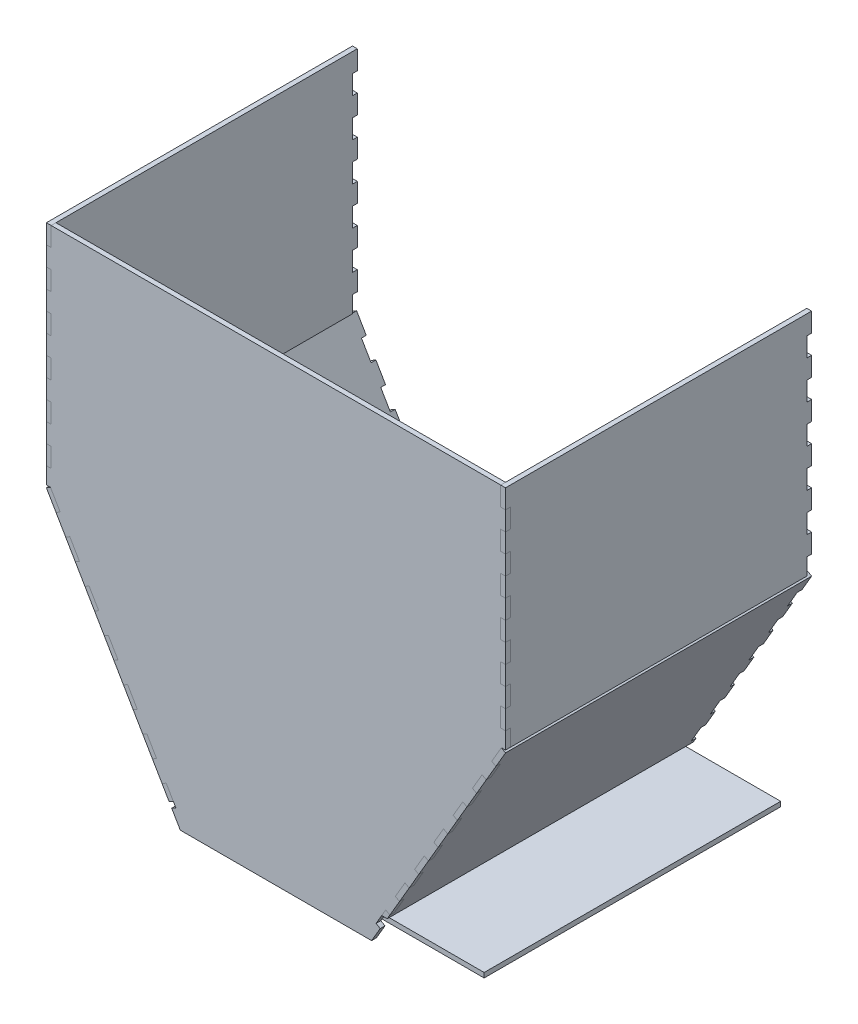
from build123d import *

# Parameters (mm, degrees)
SKETCH1_W               = 304.8
SKETCH1_H               = 152.4
BOSS_EXTRUDE1_DEPTH     = 3.175
SKETCH2_W               = 3.175
SKETCH2_H               = 12.7
CUT_EXTRUDE1_DEPTH      = 3.175
BOSS_EXTRUDE2_DEPTH     = 3.175
BOSS_EXTRUDE3_DEPTH     = 3.175
CUT_EXTRUDE2_DEPTH      = 965.327
CUT_EXTRUDE2_DEPTH_BACK = 965.327
CUT_EXTRUDE3_DEPTH      = 965.327
SKETCH7_W               = 203.2
SKETCH7_H               = 3.175
BOSS_EXTRUDE4_DEPTH     = 196.85


with BuildPart() as part:
    # Sketch1 → Boss-Extrude1 (new body)
    with BuildSketch(Plane.XY):
        Rectangle(SKETCH1_W, SKETCH1_H)
        Polygon((-63.5, -228.6), (63.5, -228.6), (152.4, -76.2), (-152.4, -76.2), align=None)
    extrude(amount=BOSS_EXTRUDE1_DEPTH)

    # Sketch2 → Cut-Extrude1 (cut)
    with BuildSketch(Plane.XY.offset(3.175)):
        with Locations((-150.8125, 69.85)):
            Rectangle(SKETCH2_W, SKETCH2_H)
        with Locations((-150.8125, 44.45)):
            Rectangle(SKETCH2_W, SKETCH2_H)
        with Locations((-150.8125, 19.05)):
            Rectangle(SKETCH2_W, SKETCH2_H)
        with Locations((-150.8125, -6.35)):
            Rectangle(SKETCH2_W, SKETCH2_H)
        with Locations((-150.8125, -31.75)):
            Rectangle(SKETCH2_W, SKETCH2_H)
        with Locations((-150.8125, -57.15)):
            Rectangle(SKETCH2_W, SKETCH2_H)
        Polygon((-143.258339965, -85.570201535), (-149.65750199, -74.600209494), (-152.4, -76.2), (-146.000837976, -87.169992041), align=None)
        Polygon((-136.859177941, -96.540193577), (-139.601675952, -98.139984083), (-133.202513928, -109.109976124), (-130.460015917, -107.510185618), align=None)
        Polygon((-124.060853893, -118.48017766), (-126.803351903, -120.079968166), (-120.404189879, -131.049960207), (-117.661691869, -129.450169701), align=None)
        Polygon((-111.262529845, -140.420161742), (-114.005027855, -142.019952248), (-107.605865831, -152.98994429), (-104.863367821, -151.390153784), align=None)
        Polygon((-98.464205796, -162.360145825), (-101.206703807, -163.959936331), (-94.807541783, -174.929928373), (-92.065043772, -173.330137867), align=None)
        Polygon((-85.665881748, -184.300129908), (-88.408379758, -185.899920414), (-82.009217734, -196.869912456), (-79.266719724, -195.270121949), align=None)
        Polygon((-72.8675577, -206.240113991), (-75.61005571, -207.839904497), (-69.210893686, -218.809896538), (-66.468395676, -217.210106032), align=None)
        Polygon((69.210893686, -218.809896538), (75.61005571, -207.839904497), (72.8675577, -206.240113991), (66.468395676, -217.210106032), align=None)
        Polygon((82.009217734, -196.869912456), (88.408379758, -185.899920414), (85.665881748, -184.300129908), (79.266719724, -195.270121949), align=None)
        Polygon((94.807541783, -174.929928373), (101.206703807, -163.959936331), (98.464205796, -162.360145825), (92.065043772, -173.330137867), align=None)
        Polygon((107.605865831, -152.98994429), (114.005027855, -142.019952248), (111.262529845, -140.420161742), (104.863367821, -151.390153784), align=None)
        Polygon((120.404189879, -131.049960207), (126.803351903, -120.079968166), (124.060853893, -118.48017766), (117.661691869, -129.450169701), align=None)
        Polygon((133.202513928, -109.109976124), (139.601675952, -98.139984083), (136.859177941, -96.540193577), (130.460015917, -107.510185618), align=None)
        with Locations((150.8125, -57.15)):
            Rectangle(SKETCH2_W, SKETCH2_H)
        with Locations((150.8125, -31.75)):
            Rectangle(SKETCH2_W, SKETCH2_H)
        with Locations((150.8125, -6.35)):
            Rectangle(SKETCH2_W, SKETCH2_H)
        with Locations((150.8125, 19.05)):
            Rectangle(SKETCH2_W, SKETCH2_H)
        with Locations((150.8125, 44.45)):
            Rectangle(SKETCH2_W, SKETCH2_H)
        with Locations((150.8125, 69.85)):
            Rectangle(SKETCH2_W, SKETCH2_H)
        Polygon((-149.65750199, -74.600209494), (-152.4, -74.600209494), (-152.4, -76.2), align=None)
        Polygon((152.4, -76.2), (152.4, -74.600209494), (149.65750199, -74.600209494), (143.258339965, -85.570201535), (146.000837976, -87.169992041), align=None)
    extrude(amount=-CUT_EXTRUDE1_DEPTH, mode=Mode.SUBTRACT)


with BuildPart() as body_2:
    # Sketch3 → Boss-Extrude2 (new body)
    with BuildSketch(Plane.ZY.offset(149.225)):
        Polygon((3.175, 63.5), (3.175, 76.2), (-200.025, 76.2), (-200.025, 63.5), (-196.85, 63.5), (-196.85, 50.8), (-200.025, 50.8), (-200.025, 38.1), (-196.85, 38.1), (-196.85, 25.4), (-200.025, 25.4), (-200.025, 12.7), (-196.85, 12.7), (-196.85, 0), (-200.025, 0), (-200.025, -12.7), (-196.85, -12.7), (-196.85, -25.4), (-200.025, -25.4), (-200.025, -38.1), (-196.85, -38.1), (-196.85, -50.8), (-200.025, -50.8), (-200.025, -63.5), (-196.85, -63.5), (-196.85, -74.600209494), (0, -74.600209494), (0, -63.5), (3.175, -63.5), (3.175, -50.8), (0, -50.8), (0, -38.1), (3.175, -38.1), (3.175, -25.4), (0, -25.4), (0, -12.7), (3.175, -12.7), (3.175, 0), (0, 0), (0, 12.7), (3.175, 12.7), (3.175, 25.4), (0, 25.4), (0, 38.1), (3.175, 38.1), (3.175, 50.8), (0, 50.8), (0, 63.5), align=None)
    extrude(amount=BOSS_EXTRUDE2_DEPTH)


with BuildPart() as body_3:
    # Sketch4 → Boss-Extrude3 (new body)
    with BuildSketch(Plane(origin=(-144.13004085, -84.075857162, 0), x_dir=(0, 0, 1), z_dir=(-0.863778901, -0.503871026, 0))):
        Polygon((3.175, -1.730007959), (3.175, 10.969992041), (-200.025, 10.969992041), (-200.025, -1.730007959), (-196.85, -1.730007959), (-196.85, -14.430007959), (-200.025, -14.430007959), (-200.025, -27.130007959), (-196.85, -27.130007959), (-196.85, -39.830007959), (-200.025, -39.830007959), (-200.025, -52.530007959), (-196.85, -52.530007959), (-196.85, -65.230007959), (-200.025, -65.230007959), (-200.025, -77.930007959), (-196.85, -77.930007959), (-196.85, -90.630007959), (-200.025, -90.630007959), (-200.025, -103.330007959), (-196.85, -103.330007959), (-196.85, -116.030007959), (-200.025, -116.030007959), (-200.025, -128.730007959), (-196.85, -128.730007959), (-196.85, -141.430007959), (-200.025, -141.430007959), (-200.025, -154.130007959), (-196.85, -154.130007959), (-196.85, -165.464046625), (0, -165.464046625), (0, -154.130007959), (3.175, -154.130007959), (3.175, -141.430007959), (0, -141.430007959), (0, -128.730007959), (3.175, -128.730007959), (3.175, -116.030007959), (0, -116.030007959), (0, -103.330007959), (3.175, -103.330007959), (3.175, -90.630007959), (0, -90.630007959), (0, -77.930007959), (3.175, -77.930007959), (3.175, -65.230007959), (0, -65.230007959), (0, -52.530007959), (3.175, -52.530007959), (3.175, -39.830007959), (0, -39.830007959), (0, -27.130007959), (3.175, -27.130007959), (3.175, -14.430007959), (0, -14.430007959), (0, -1.730007959), align=None)
    extrude(amount=BOSS_EXTRUDE3_DEPTH)

    # Sketch5 → Cut-Extrude2 (cut, two sides)
    with BuildSketch(Plane(origin=(0, 0, 0), x_dir=(-1, 0, 0), z_dir=(0, 0, -1))) as cut_extrude2_sk:
        Polygon((70.908333333, -215.9), (68.165835323, -214.300209494), (67.232624194, -215.9), (-127.012896649, -215.9), (-127.012896649, -228.6), (120.270461676, -228.6), (120.270461676, -215.9), align=None)
    extrude(amount=CUT_EXTRUDE2_DEPTH, mode=Mode.SUBTRACT)
    extrude(cut_extrude2_sk.sketch, amount=-CUT_EXTRUDE2_DEPTH_BACK, mode=Mode.SUBTRACT)


with BuildPart() as body_4:
    # Mirror1: mirrored copy
    add(body_2.part.mirror(Plane(origin=(0, 0, 0), x_dir=(0, 0, 1), z_dir=(1, 0, 0))))


with BuildPart() as body_5:
    # Mirror1 2: mirrored copy
    add(body_3.part.mirror(Plane(origin=(0, 0, 0), x_dir=(0, 0, 1), z_dir=(1, 0, 0))))

    # Sketch6 → Cut-Extrude3 (cut)
    with BuildSketch(Plane(origin=(0, 0, -200.025), x_dir=(-1, 0, 0), z_dir=(0, 0, -1))):
        Polygon((-68.165835323, -214.300209494), (-70.195957528, -210.82), (-73.871666667, -210.82), (-70.908333333, -215.9), align=None)
    extrude(amount=-CUT_EXTRUDE3_DEPTH, mode=Mode.SUBTRACT)


with BuildPart() as body_6:
    # Sketch7 → Boss-Extrude4 (new body)
    with BuildSketch(Plane(origin=(0, 0, 0), x_dir=(-1, 0, 0), z_dir=(0, 0, -1))):
        with Locations((-33.434164677, -214.3125)):
            Rectangle(SKETCH7_W, SKETCH7_H)
    extrude(amount=BOSS_EXTRUDE4_DEPTH)


solid = Compound([part.part, body_2.part, body_3.part, body_4.part, body_5.part, body_6.part])
